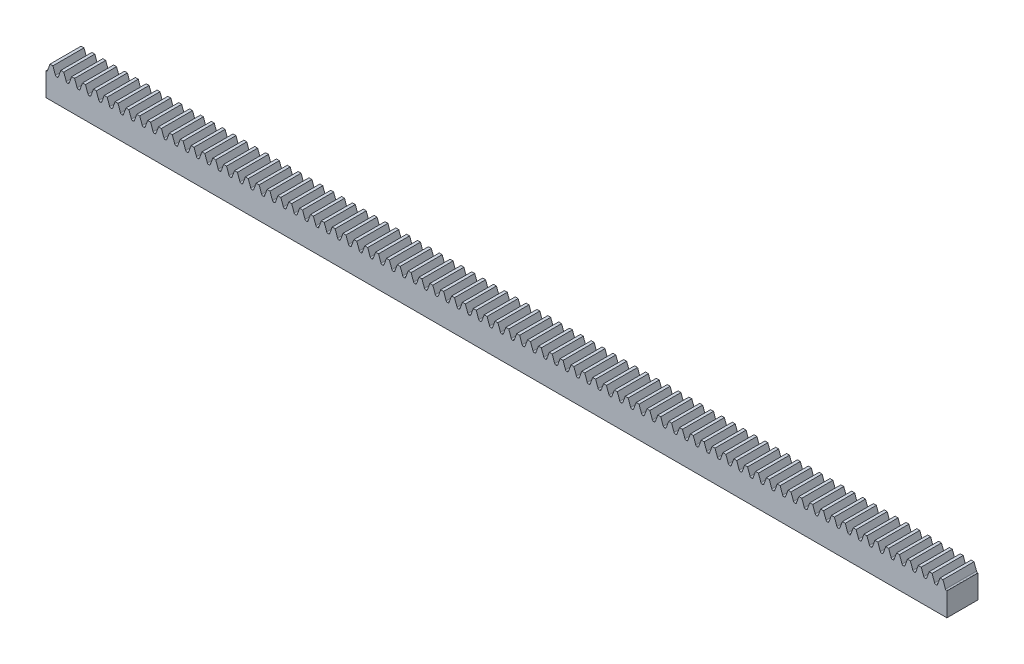
from build123d import *

# Parameters (mm, degrees)
SECTION_CREMAILLERE_W      = 9
SECTION_CREMAILLERE_H      = 9.785398165
BASE_EXTRUSION_DEPTH       = 260.75219078
ENL_V_START                = -5.5
ENL_V_MAT_EXTRU_2_DEPTH    = 105.5
R_P_TITION_LIN_AIRE1_COUNT = 83
R_P_TITION_LIN_AIRE1_PITCH = 3.14159266
ESQUISSE3_R                = 1.65
ENL_V_MAT_EXTRU_3_DEPTH    = 5.5


with BuildPart() as part:
    # Section Cremaillere → Base-Extrusion (new body)
    with BuildSketch(Plane(origin=(-0.785398165, 0, 0), x_dir=(0, 0, -1), z_dir=(1, 0, 0))):
        with Locations((0, -3.107300917)):
            Rectangle(SECTION_CREMAILLERE_W, SECTION_CREMAILLERE_H)
    extrude(amount=BASE_EXTRUSION_DEPTH)

    # Esquisse1 → Enlèv. mat.-Extru.2 (cut)
    with BuildSketch(Plane.XY.offset(ENL_V_START)):
        with BuildLine():
            Line((0.363895662, 1), (-0.363875335, -0.99994414))
            ThreePointArc((-0.363875335, -0.99994414), (-0.502997794, -1.1812706), (-0.720967089, -1.25))
            Line((-0.720967089, -1.25), (-0.785398165, -1.25))
            Line((-0.785398165, -1.25), (-0.785398165, 1.785398165))
            Line((-0.785398165, 1.785398165), (2.356194495, 1.785398165))
            Line((2.356194495, 1.785398165), (2.356194495, -1.25))
            Line((2.356194495, -1.25), (2.291763419, -1.25))
            ThreePointArc((2.291763419, -1.25), (2.073794124, -1.1812706), (1.934671665, -0.99994414))
            Line((1.934671665, -0.99994414), (1.206900668, 1))
            Line((1.206900668, 1), (0.363895662, 1))
        make_face()
    enl_v_mat_extru_2 = extrude(amount=ENL_V_MAT_EXTRU_2_DEPTH, mode=Mode.SUBTRACT)

    # Répétition linéaire1: Enlèv. mat.-Extru.2 ×83
    with Locations(*[(i * R_P_TITION_LIN_AIRE1_PITCH, 0, 0) for i in range(1, R_P_TITION_LIN_AIRE1_COUNT)]):
        add(enl_v_mat_extru_2, mode=Mode.SUBTRACT)

    # Esquisse3 → Enlèv. mat.-Extru.3 (cut)
    with BuildSketch(Plane.XZ.offset(8)):
        with Locations((42.673300298, 0)):
            Circle(ESQUISSE3_R)
        with Locations((129.590697225, 0)):
            Circle(ESQUISSE3_R)
        with Locations((216.508094152, 0)):
            Circle(ESQUISSE3_R)
    extrude(amount=-ENL_V_MAT_EXTRU_3_DEPTH, mode=Mode.SUBTRACT)


solid = part.part
